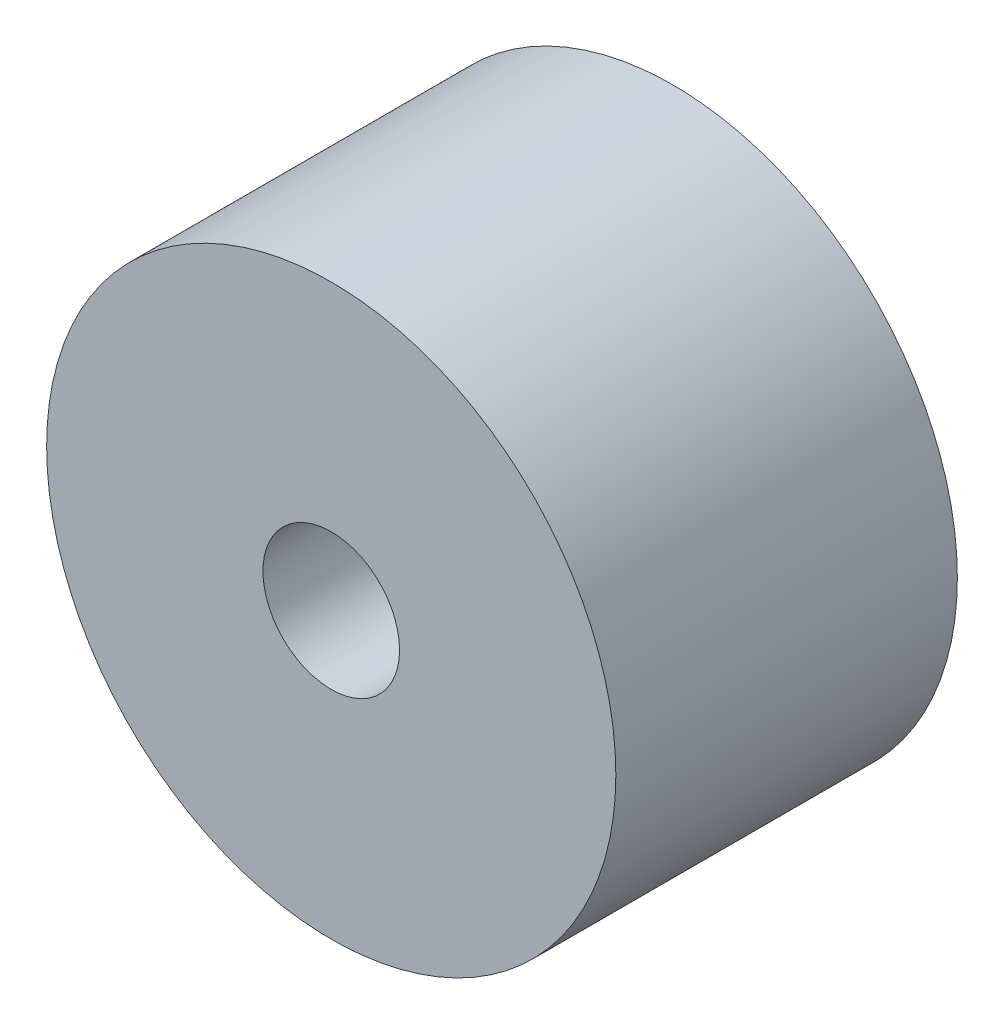
from build123d import *

# Parameters (mm, degrees)
SKETCH_1_R      = 25
SKETCH_1_R_2    = 6
EXTRUDE_1_DEPTH = 30


with BuildPart() as part:
    # 草图1 → 凸台-拉伸1 (new body)
    with BuildSketch(Plane.XY):
        Circle(SKETCH_1_R)
        Circle(SKETCH_1_R_2, mode=Mode.SUBTRACT)
    extrude(amount=EXTRUDE_1_DEPTH)


solid = part.part
